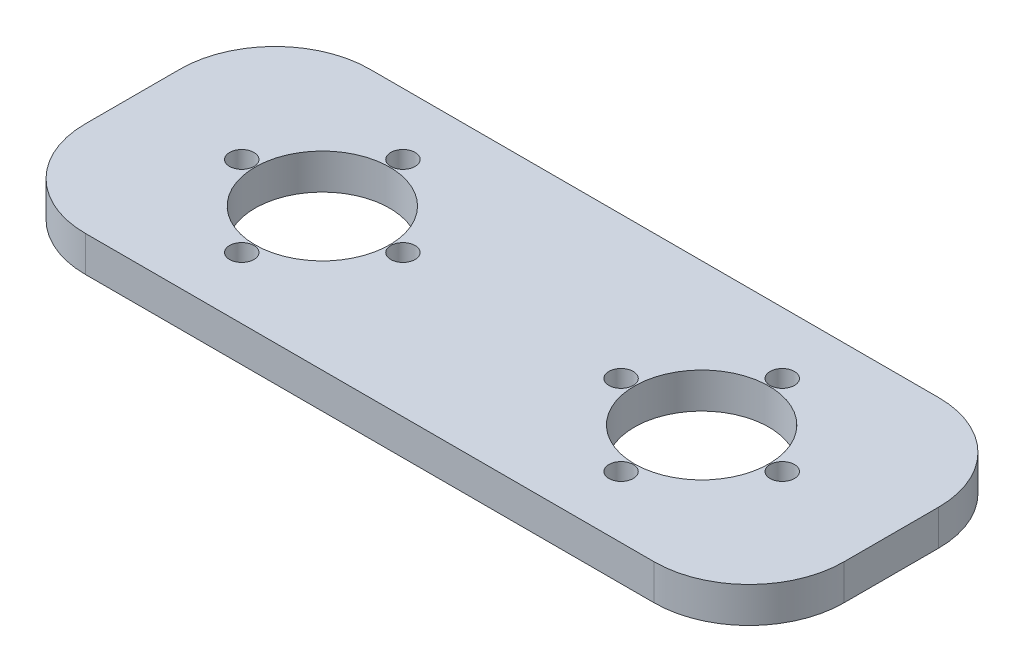
from build123d import *

# Parameters (mm, degrees)
SKETCH1_W                 = 101.6
SKETCH1_H                 = 38.1
SKETCH1_R                 = 9.017
BOSS_EXTRUDE1_DEPTH       = 4.7625
F_4_CLEARANCE_HOLE1_D     = 3.2639
F_4_CLEARANCE_HOLE1_DEPTH = 25.4
F_4_CLEARANCE_HOLE1_TIP   = 0.980574487
FILLET1_R                 = 12.7


with BuildPart() as part:
    # Sketch1 → Boss-Extrude1 (new body)
    with BuildSketch(Plane(origin=(0, 0, 0), x_dir=(1, 0, 0), z_dir=(0, 1, 0))):
        with Locations((50.8, 19.05)):
            Rectangle(SKETCH1_W, SKETCH1_H)
        with Locations((25.4, 19.05)):
            Circle(SKETCH1_R, mode=Mode.SUBTRACT)
        with Locations((76.2, 19.05)):
            Circle(SKETCH1_R, mode=Mode.SUBTRACT)
    extrude(amount=BOSS_EXTRUDE1_DEPTH)

    # #4 Clearance Hole1
    with Locations(Plane(origin=(0, 4.7625, 0), x_dir=(-1, 0, 0), z_dir=(0, 1, 0))):
        with Locations((-25.4, -29.845), (-36.195, -19.05), (-25.4, -8.255), (-14.605, -19.05), (-65.405, -19.05), (-76.2, -29.845), (-86.995, -19.05), (-76.2, -8.255)):
            Hole(F_4_CLEARANCE_HOLE1_D / 2, depth=F_4_CLEARANCE_HOLE1_DEPTH)
            with Locations((0, 0, -(F_4_CLEARANCE_HOLE1_DEPTH + F_4_CLEARANCE_HOLE1_TIP / 2))):  # 118° drill point
                Cone(0, F_4_CLEARANCE_HOLE1_D / 2, F_4_CLEARANCE_HOLE1_TIP, mode=Mode.SUBTRACT)

    # Fillet1
    fillet1_edges = [part.edges().sort_by_distance(p)[0] for p in [
        (0, 2.38125, -38.1),
        (101.6, 2.38125, -38.1),
        (101.6, 2.38125, 0),
        (0, 2.38125, 0),
    ]]
    fillet(fillet1_edges, radius=FILLET1_R)


solid = part.part
